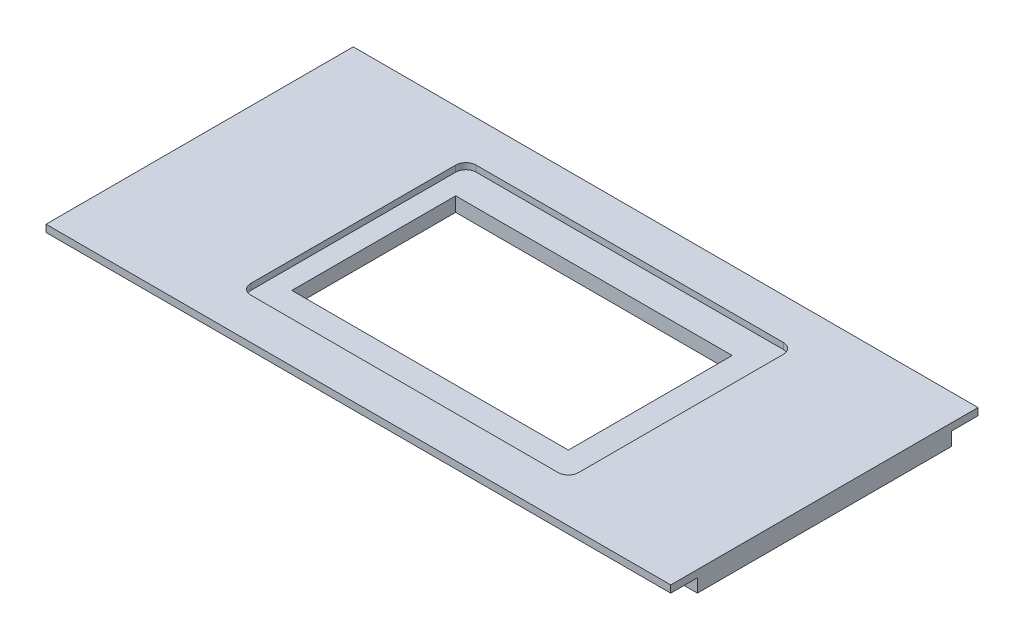
from build123d import *

# Parameters (mm, degrees)
SKETCH2_W           = 305
SKETCH2_H           = 150
BOSS_EXTRUDE1_DEPTH = 5
SKETCH3_W           = 13
SKETCH3_H           = 6.5
CUT_EXTRUDE1_DEPTH  = 305
SKETCH4_W           = 160
SKETCH4_H           = 110
CUT_EXTRUDE2_DEPTH  = 3
FILLET1_R           = 5
SKETCH5_W           = 135
SKETCH5_H           = 80
CUT_EXTRUDE3_DEPTH  = 8


with BuildPart() as part:
    # Sketch2 → Boss-Extrude1 (new body, symmetric)
    with BuildSketch(Plane(origin=(0, 0, 0), x_dir=(1, 0, 0), z_dir=(0, 1, 0))):
        Rectangle(SKETCH2_W, SKETCH2_H)
    extrude(amount=BOSS_EXTRUDE1_DEPTH, both=True)

    # Sketch3 → Cut-Extrude1 (cut)
    with BuildSketch(Plane(origin=(152.5, 0, 0), x_dir=(0, 0, -1), z_dir=(1, 0, 0))):
        with Locations((-68.5, -1.75)):
            Rectangle(SKETCH3_W, SKETCH3_H)
        with Locations((68.5, -1.75)):
            Rectangle(SKETCH3_W, SKETCH3_H)
    extrude(amount=-CUT_EXTRUDE1_DEPTH, mode=Mode.SUBTRACT)

    # Sketch4 → Cut-Extrude2 (cut)
    with BuildSketch(Plane(origin=(0, 5, 0), x_dir=(1, 0, 0), z_dir=(0, 1, 0))):
        with Locations((2.5, 0)):
            Rectangle(SKETCH4_W, SKETCH4_H)
    extrude(amount=-CUT_EXTRUDE2_DEPTH, mode=Mode.SUBTRACT)

    # Fillet1
    fillet1_edges = [part.edges().sort_by_distance(p)[0] for p in [
        (-77.5, 3.5, 55),
        (-77.5, 3.5, -55),
        (82.5, 3.5, -55),
        (82.5, 3.5, 55),
    ]]
    fillet(fillet1_edges, radius=FILLET1_R)

    # Sketch5 → Cut-Extrude3 (cut, through all)
    with BuildSketch(Plane(origin=(0, 2, 0), x_dir=(1, 0, 0), z_dir=(0, 1, 0))):
        Rectangle(SKETCH5_W, SKETCH5_H)
    extrude(amount=-CUT_EXTRUDE3_DEPTH, mode=Mode.SUBTRACT)


solid = part.part
